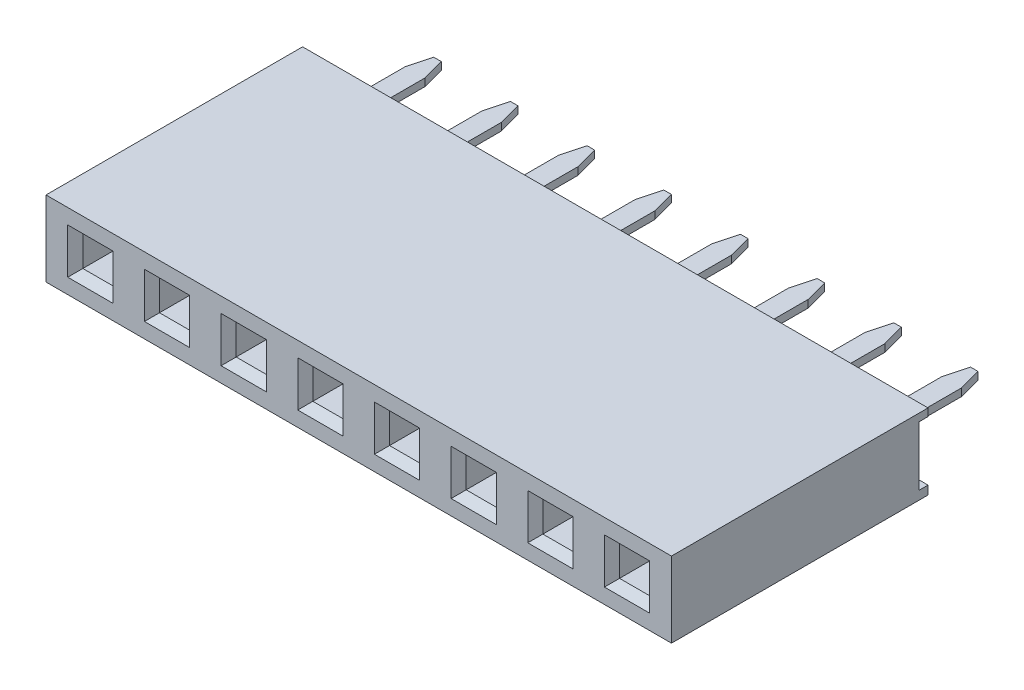
from build123d import *

# Parameters (mm, degrees)
SKETCH1_W                  = 20.72
SKETCH1_H                  = 2.5
BOSS_EXTRUDE1_DEPTH        = 8.5
SKETCH2_W                  = 1
SKETCH2_H                  = 1
CUT_EXTRUDE1_DEPTH         = 2.25
CHAMFER1_SIZE              = 0.25
SKETCH3_W                  = 0.3
SKETCH3_H                  = 1.963850618
CUT_EXTRUDE2_DEPTH         = 21.72
SKETCH4_W                  = 0.65
SKETCH4_H                  = 3.3
BOSS_EXTRUDE2_DEPTH        = 0.125
CHAMFER2_SIZE              = 0.2
CHAMFER2_SIZE2             = 0.746410162
LPATTERN4_COUNT            = 8
LPATTERN4_PITCH            = 2.54
LPATTERN5_COUNT            = 8
LPATTERN5_PITCH            = 2.54
CHAMFER1_OF_LPATTERN5_SIZE = 0.25


with BuildPart() as part:
    # Sketch1 → Boss-Extrude1 (new body)
    with BuildSketch(Plane.XY):
        with Locations((10.36, 1.25)):
            Rectangle(SKETCH1_W, SKETCH1_H)
    extrude(amount=BOSS_EXTRUDE1_DEPTH)

    # Sketch2 → Cut-Extrude1 (cut)
    with BuildSketch(Plane.XY.offset(8.5)):
        with Locations((1.47, 1.25)):
            Rectangle(SKETCH2_W, SKETCH2_H)
    cut_extrude1 = extrude(amount=-CUT_EXTRUDE1_DEPTH, mode=Mode.SUBTRACT)

    # Chamfer1
    chamfer1_edges = [part.edges().sort_by_distance(p)[0] for p in [
        (0.97, 1.25, 8.5),
        (1.47, 0.75, 8.5),
        (1.97, 1.25, 8.5),
        (1.47, 1.75, 8.5),
    ]]
    chamfer(chamfer1_edges, length=CHAMFER1_SIZE)

    # Sketch3 → Cut-Extrude2 (cut, through all)
    with BuildSketch(Plane.ZY):
        with Locations((0.15, 1.268074691)):
            Rectangle(SKETCH3_W, SKETCH3_H)
    extrude(amount=-CUT_EXTRUDE2_DEPTH, mode=Mode.SUBTRACT)

    # LPattern5: Cut-Extrude1 ×8
    with Locations(*[(i * LPATTERN5_PITCH, 0, 0) for i in range(1, LPATTERN5_COUNT)]):
        add(cut_extrude1, mode=Mode.SUBTRACT)

    # Chamfer1 of LPattern5
    chamfer1_of_lpattern5_edges = [part.edges().sort_by_distance(p)[0] for p in [
        (3.51, 1.25, 8.5),
        (4.01, 0.75, 8.5),
        (4.51, 1.25, 8.5),
        (4.01, 1.75, 8.5),
        (6.05, 1.25, 8.5),
        (6.55, 0.75, 8.5),
        (7.05, 1.25, 8.5),
        (6.55, 1.75, 8.5),
        (8.59, 1.25, 8.5),
        (9.09, 0.75, 8.5),
        (9.59, 1.25, 8.5),
        (9.09, 1.75, 8.5),
        (11.13, 1.25, 8.5),
        (11.63, 0.75, 8.5),
        (12.13, 1.25, 8.5),
        (11.63, 1.75, 8.5),
        (13.67, 1.25, 8.5),
        (14.17, 0.75, 8.5),
        (14.67, 1.25, 8.5),
        (14.17, 1.75, 8.5),
        (16.21, 1.25, 8.5),
        (16.71, 0.75, 8.5),
        (17.21, 1.25, 8.5),
        (16.71, 1.75, 8.5),
        (18.75, 1.25, 8.5),
        (19.25, 0.75, 8.5),
        (19.75, 1.25, 8.5),
        (19.25, 1.75, 8.5),
    ]]
    chamfer(chamfer1_of_lpattern5_edges, length=CHAMFER1_OF_LPATTERN5_SIZE)


with BuildPart() as body_2:
    # Sketch4 → Boss-Extrude2 (new body, symmetric)
    with BuildSketch(Plane(origin=(0, 1.25, 0), x_dir=(-1, 0, 0), z_dir=(0, -1, 0))):
        with Locations((-1.47, 1.35)):
            Rectangle(SKETCH4_W, SKETCH4_H)
    extrude(amount=BOSS_EXTRUDE2_DEPTH, both=True)

    # Chamfer2
    chamfer2_edges = [body_2.edges().sort_by_distance(p)[0] for p in [
        (1.795, 1.25, -3),
        (1.145, 1.25, -3),
    ]]
    chamfer2_side = [body_2.faces().sort_by_distance(p)[0] for p in [
        (1.47, 1.25, -3),
    ]]
    chamfer(chamfer2_edges, length=CHAMFER2_SIZE, length2=CHAMFER2_SIZE2, reference=chamfer2_side[0])


with BuildPart() as lpattern4_1:
    # LPattern4: pattern copy
    add(body_2.part.moved(Location(Vector(1, 0, 0) * (1 * LPATTERN4_PITCH))))


with BuildPart() as lpattern4_2:
    # LPattern4: pattern copy
    add(body_2.part.moved(Location(Vector(1, 0, 0) * (2 * LPATTERN4_PITCH))))


with BuildPart() as lpattern4_3:
    # LPattern4: pattern copy
    add(body_2.part.moved(Location(Vector(1, 0, 0) * (3 * LPATTERN4_PITCH))))


with BuildPart() as lpattern4_4:
    # LPattern4: pattern copy
    add(body_2.part.moved(Location(Vector(1, 0, 0) * (4 * LPATTERN4_PITCH))))


with BuildPart() as lpattern4_5:
    # LPattern4: pattern copy
    add(body_2.part.moved(Location(Vector(1, 0, 0) * (5 * LPATTERN4_PITCH))))


with BuildPart() as lpattern4_6:
    # LPattern4: pattern copy
    add(body_2.part.moved(Location(Vector(1, 0, 0) * (6 * LPATTERN4_PITCH))))


with BuildPart() as lpattern4_7:
    # LPattern4: pattern copy
    add(body_2.part.moved(Location(Vector(1, 0, 0) * (7 * LPATTERN4_PITCH))))


solid = Compound([part.part, body_2.part, lpattern4_1.part, lpattern4_2.part, lpattern4_3.part, lpattern4_4.part, lpattern4_5.part, lpattern4_6.part, lpattern4_7.part])
